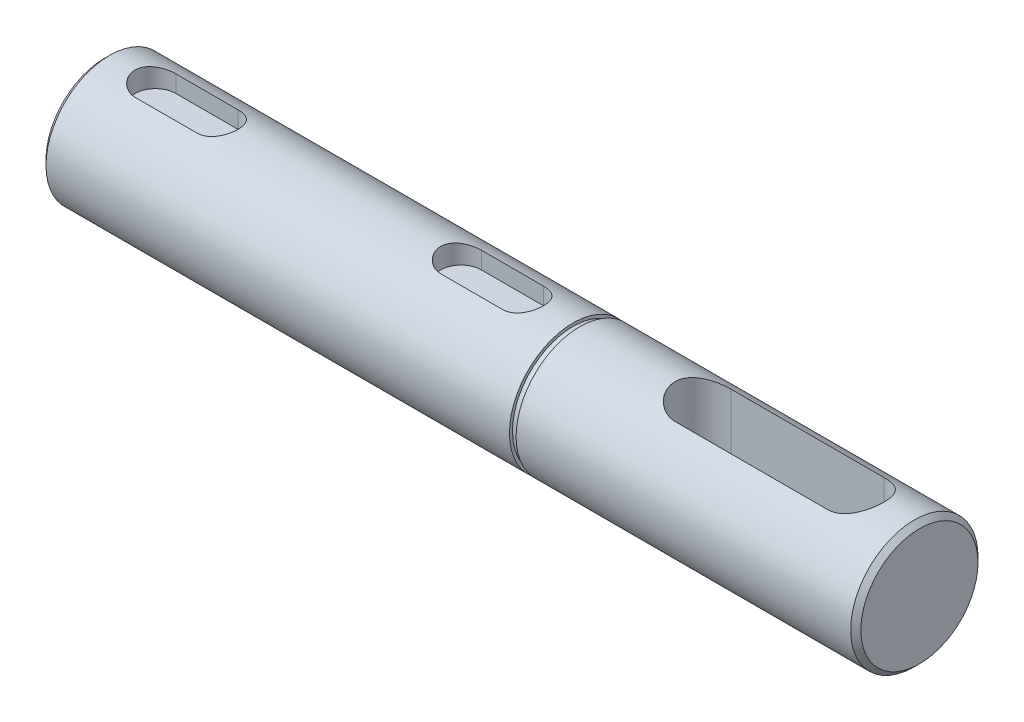
from build123d import *

# Parameters (mm, degrees)
SKETCH_1_R               = 15
EXTRUDE_1_DEPTH          = 160
SKETCH_2_OUTSIDE_W       = 65.106
SKETCH_2_OUTSIDE_H       = 65.106
SKETCH_2_OUTSIDE_R       = 12.5
CUT_EXTRUDE_1_DEPTH      = 92
SKETCH_3_OUTSIDE_W       = 65.106
SKETCH_3_OUTSIDE_H       = 65.106
SKETCH_3_OUTSIDE_R       = 12.5
CUT_EXTRUDE_2_DEPTH      = 63
CHAMFER_1_SIZE           = 1
CUT_EXTRUDE_START        = 12.5
CUT_EXTRUDE_3_DEPTH      = 4
HOLE_WIZARD_M121_D       = 10.2
HOLE_WIZARD_M121_DEPTH   = 32.75
HOLE_WIZARD_M121_TIP     = 2.944486373
CHAMFER_2_SIZE           = 1
CUT_EXTRUDE_4_DEPTH      = 16
CUT_EXTRUDE_4_DEPTH_BACK = 16
SKETCH_9_R               = 15
SKETCH_9_R_2             = 11.9
CUT_EXTRUDE_5_DEPTH      = 1.3
SKETCH_10_R              = 15
SKETCH_10_R_2            = 12.5
CUT_EXTRUDE_6_DEPTH      = 7.3


with BuildPart() as part:
    # Эскиз1 → Бобышка-Вытянуть1 (new body)
    with BuildSketch(Plane(origin=(0, 0, 0), x_dir=(0, 0, -1), z_dir=(1, 0, 0))):
        Circle(SKETCH_1_R)
    extrude(amount=EXTRUDE_1_DEPTH)

    # Эскиз2 outside → Вырез-Вытянуть1 (cut)
    with BuildSketch(Plane.ZY):
        Rectangle(SKETCH_2_OUTSIDE_W, SKETCH_2_OUTSIDE_H)
        Circle(SKETCH_2_OUTSIDE_R, mode=Mode.SUBTRACT)
    extrude(amount=-CUT_EXTRUDE_1_DEPTH, mode=Mode.SUBTRACT)

    # Эскиз3 outside → Вырез-Вытянуть2 (cut)
    with BuildSketch(Plane(origin=(160, 0, 0), x_dir=(0, 0, -1), z_dir=(1, 0, 0))):
        Rectangle(SKETCH_3_OUTSIDE_W, SKETCH_3_OUTSIDE_H)
        Circle(SKETCH_3_OUTSIDE_R, mode=Mode.SUBTRACT)
    extrude(amount=-CUT_EXTRUDE_2_DEPTH, mode=Mode.SUBTRACT)

    # Фаска1
    chamfer_1_edges = [part.edges().sort_by_distance(p)[0] for p in [
        (0, 0, -12.5),
        (97, 0, 15),
        (160, 0, 12.5),
        (92, 0, 15),
    ]]
    chamfer(chamfer_1_edges, length=CHAMFER_1_SIZE)

    # Эскиз4 → Вырез-Вытянуть3 (cut)
    with BuildSketch(Plane(origin=(0, 0, 0), x_dir=(1, 0, 0), z_dir=(0, 1, 0)).offset(CUT_EXTRUDE_START)):
        with BuildLine():
            Line((10, 4), (22.2, 4))
            ThreePointArc((22.2, 4), (26.2, 0), (22.2, -4))
            Line((22.2, -4), (10, -4))
            ThreePointArc((10, -4), (6, 0), (10, 4))
        make_face()
        with BuildLine():
            Line((70, 4), (82.2, 4))
            ThreePointArc((82.2, 4), (86.2, 0), (82.2, -4))
            Line((82.2, -4), (70, -4))
            ThreePointArc((70, -4), (66, 0), (70, 4))
        make_face()
    extrude(amount=-CUT_EXTRUDE_3_DEPTH, mode=Mode.SUBTRACT)

    # Отверстие обработанное метчиком M121
    with Locations(Plane.ZY):
        with Locations((0, 0)):
            Hole(HOLE_WIZARD_M121_D / 2, depth=HOLE_WIZARD_M121_DEPTH)
            with Locations((0, 0, -(HOLE_WIZARD_M121_DEPTH + HOLE_WIZARD_M121_TIP / 2))):  # 120° drill point
                Cone(0, HOLE_WIZARD_M121_D / 2, HOLE_WIZARD_M121_TIP, mode=Mode.SUBTRACT)

    # Фаска2
    chamfer_2_edges = [part.edges().sort_by_distance(p)[0] for p in [
        (0, 0, 5.1),
    ]]
    chamfer(chamfer_2_edges, length=CHAMFER_2_SIZE)

    # Эскиз8 → Вырез-Вытянуть4 (cut, two sides)
    with BuildSketch(Plane(origin=(0, 0, 0), x_dir=(1, 0, 0), z_dir=(0, 1, 0))) as cut_extrude_4_sk:
        with BuildLine():
            Line((147.5, -5.5), (117.5, -5.5))
            ThreePointArc((117.5, -5.5), (112, 0), (117.5, 5.5))
            Line((117.5, 5.5), (147.5, 5.5))
            ThreePointArc((147.5, 5.5), (153, 0), (147.5, -5.5))
        make_face()
    extrude(amount=CUT_EXTRUDE_4_DEPTH, mode=Mode.SUBTRACT)
    extrude(cut_extrude_4_sk.sketch, amount=-CUT_EXTRUDE_4_DEPTH_BACK, mode=Mode.SUBTRACT)

    # Эскиз9 → Вырез-Вытянуть5 (cut)
    with BuildSketch(Plane.ZY.offset(-92)):
        Circle(SKETCH_9_R)
        Circle(SKETCH_9_R_2, mode=Mode.SUBTRACT)
    extrude(amount=-CUT_EXTRUDE_5_DEPTH, mode=Mode.SUBTRACT)

    # Эскиз10 → Вырез-Вытянуть6 (cut)
    with BuildSketch(Plane(origin=(97, 0, 0), x_dir=(0, 0, -1), z_dir=(1, 0, 0))):
        Circle(SKETCH_10_R)
        Circle(SKETCH_10_R_2, mode=Mode.SUBTRACT)
    extrude(amount=-CUT_EXTRUDE_6_DEPTH, mode=Mode.SUBTRACT)


solid = part.part
